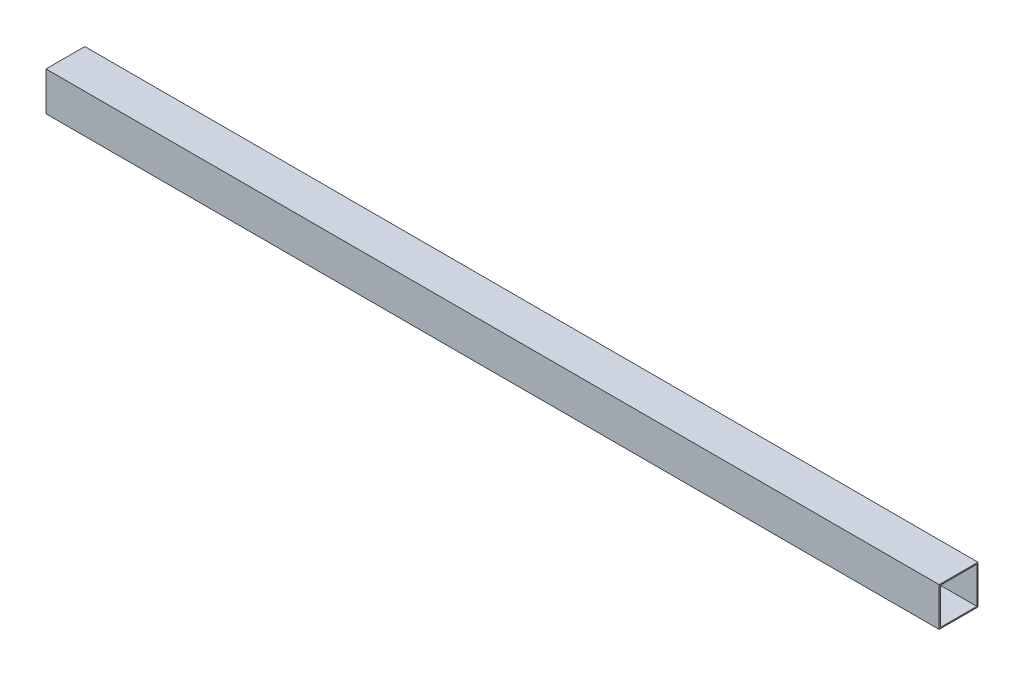
from build123d import *

# Parameters (mm, degrees)
SKETCH1_W           = 25.4
SKETCH1_H           = 25.4
SKETCH1_W_2         = 23.876
SKETCH1_H_2         = 23.876
EXTRUDE_THIN1_DEPTH = 584.2


with BuildPart() as part:
    # Sketch1 → Extrude-Thin1 (new body)
    with BuildSketch(Plane(origin=(0, 0, 0), x_dir=(0, 0, -1), z_dir=(1, 0, 0))):
        with Locations((12.7, 12.7)):
            Rectangle(SKETCH1_W, SKETCH1_H)
        with Locations((12.7, 12.7)):
            Rectangle(SKETCH1_W_2, SKETCH1_H_2, mode=Mode.SUBTRACT)
    extrude(amount=EXTRUDE_THIN1_DEPTH)


solid = part.part
